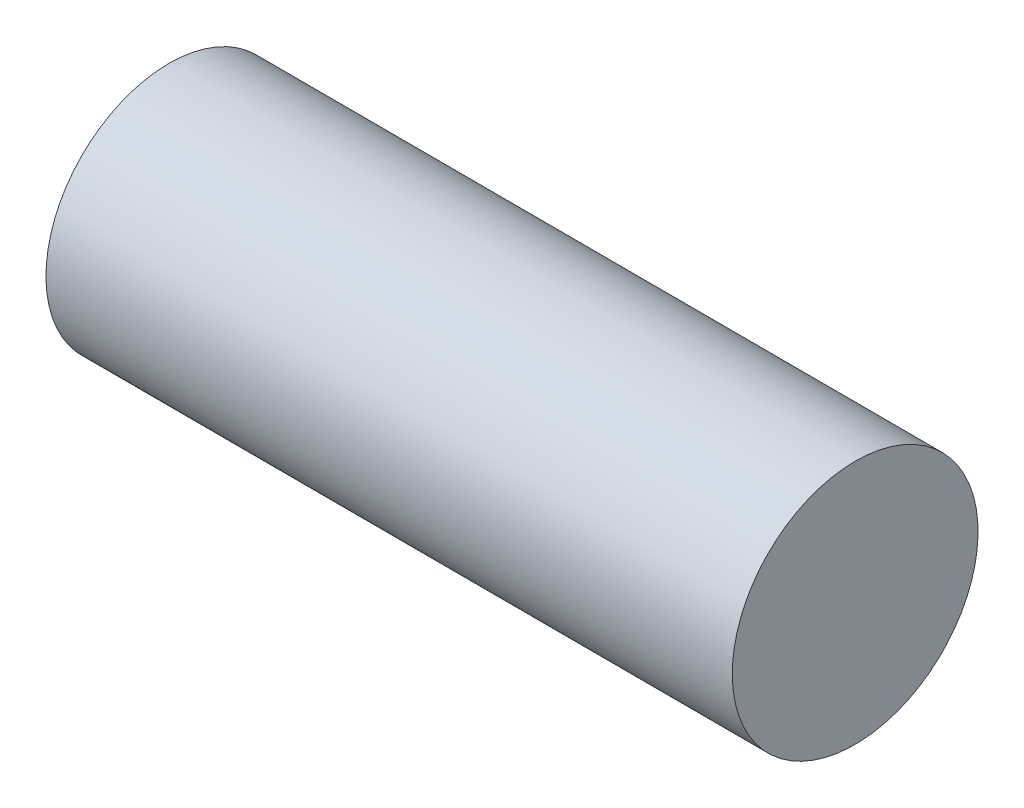
from build123d import *

# Parameters (mm, degrees)
SWEEP1_PROFILE_R = 4.699


with BuildPart() as part:
    # Sweep1: sweep along a curve in space
    with BuildLine() as sweep1_path:
        Line((-13.558042445, 200.895063598, 163.321796861), (12.685805764, 200.845332568, 163.321796809))
    # Sweep1 profile (on start of the path) → Sweep1 (sweep)
    with BuildSketch(Plane(origin=(-13.558042445, 200.895063598, 163.321796861), x_dir=(0.001894956, 0.999998205, 0), z_dir=(0.999998205, -0.001894956, -2e-09))):
        Circle(SWEEP1_PROFILE_R)
    sweep(path=sweep1_path.line)


solid = part.part
